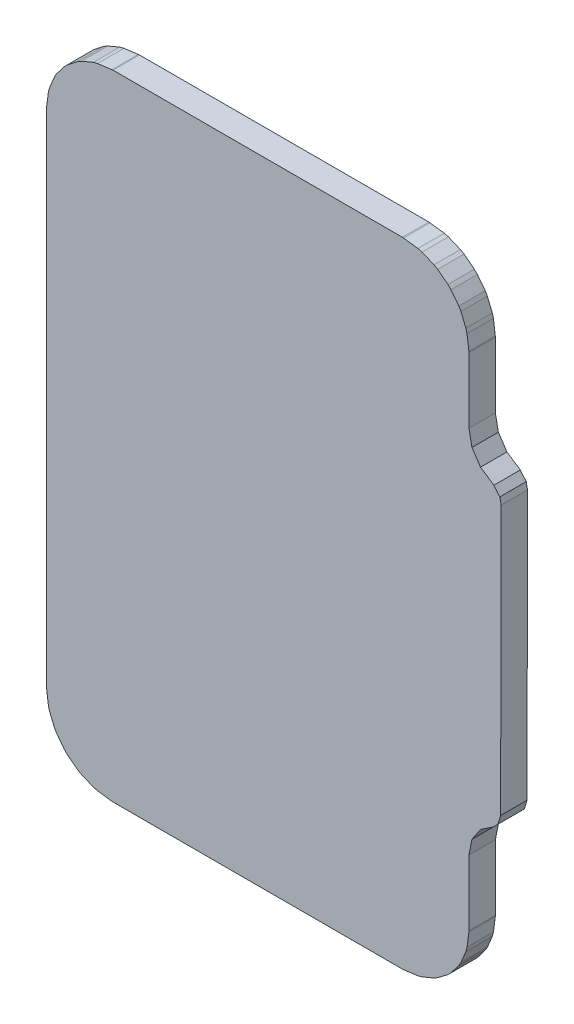
from build123d import *

# Parameters (mm, degrees)
BOSS_EXTRUDE1_DEPTH   = 0.2
BOSS_EXTRUDE1_2_DEPTH = 0.2


with BuildPart() as part:
    # Model → Boss-Extrude1 (new body)
    with BuildSketch(Plane.XY):
        Polygon((-0.7397, 1.382), (-0.6305, 1.368), (-0.5992, 1.36), (-0.5088, 1.322), (-0.4808, 1.306), (-0.4031, 1.246), (-0.3802, 1.223), (-0.3206, 1.146), (-0.3045, 1.118), (-0.267, 1.027), (-0.2586, 0.996), (-0.2442, 0.887), (-0.2437, 0.879), (-0.2437, 0.383), (-0.2209, 0.268), (-0.156, 0.171), (-0.055, 0.103), (-0.01, 0.049), (0, 0), (-0.004, -2.038), (-0.024, -2.105), (-0.06, -2.141), (-0.156, -2.205), (-0.2209, -2.302), (-0.2437, -2.417), (-0.2437, -2.913), (-0.2442, -2.921), (-0.2586, -3.03), (-0.267, -3.062), (-0.3044, -3.152), (-0.3206, -3.18), (-0.3802, -3.258), (-0.4031, -3.281), (-0.4807, -3.34), (-0.5088, -3.356), (-0.5992, -3.394), (-0.6305, -3.402), (-0.7397, -3.417), (-0.7478, -3.417), (-2.9396, -3.417), (-2.9477, -3.417), (-3.0569, -3.402), (-3.0882, -3.394), (-3.1786, -3.356), (-3.2067, -3.34), (-3.2843, -3.281), (-3.3072, -3.258), (-3.3668, -3.18), (-3.383, -3.152), (-3.4204, -3.062), (-3.4288, -3.03), (-3.4432, -2.921), (-3.4437, -2.913), (-3.4437, 0.879), (-3.4432, 0.887), (-3.4288, 0.996), (-3.4204, 1.027), (-3.3829, 1.118), (-3.3668, 1.146), (-3.3072, 1.223), (-3.2843, 1.246), (-3.2066, 1.306), (-3.1786, 1.322), (-3.0882, 1.36), (-3.0569, 1.368), (-2.9477, 1.382), (-2.9396, 1.383), (-0.7478, 1.383), align=None)
    extrude(amount=BOSS_EXTRUDE1_DEPTH)


with BuildPart() as body_2:
    # Model → Boss-Extrude1 2 (new body)
    with BuildSketch(Plane.XY):
        Polygon((25.081, 4.408), (25.127, 4.355), (25.138, 4.304), (25.138, 3.44), (25.136, 3.416), (25.128, 3.375), (25.109, 3.331), (25.093, 3.307), (25.059, 3.273), (25.035, 3.257), (24.99, 3.238), (24.95, 3.23), (24.926, 3.228), (23.85, 3.228), (23.826, 3.23), (23.786, 3.238), (23.741, 3.257), (23.717, 3.273), (23.683, 3.307), (23.667, 3.331), (23.648, 3.375), (23.64, 3.416), (23.638, 3.44), (23.638, 4.304), (23.658, 4.371), (23.711, 4.416), (23.762, 4.428), (25.014, 4.428), align=None)
    extrude(amount=BOSS_EXTRUDE1_2_DEPTH)


solid = part.part
